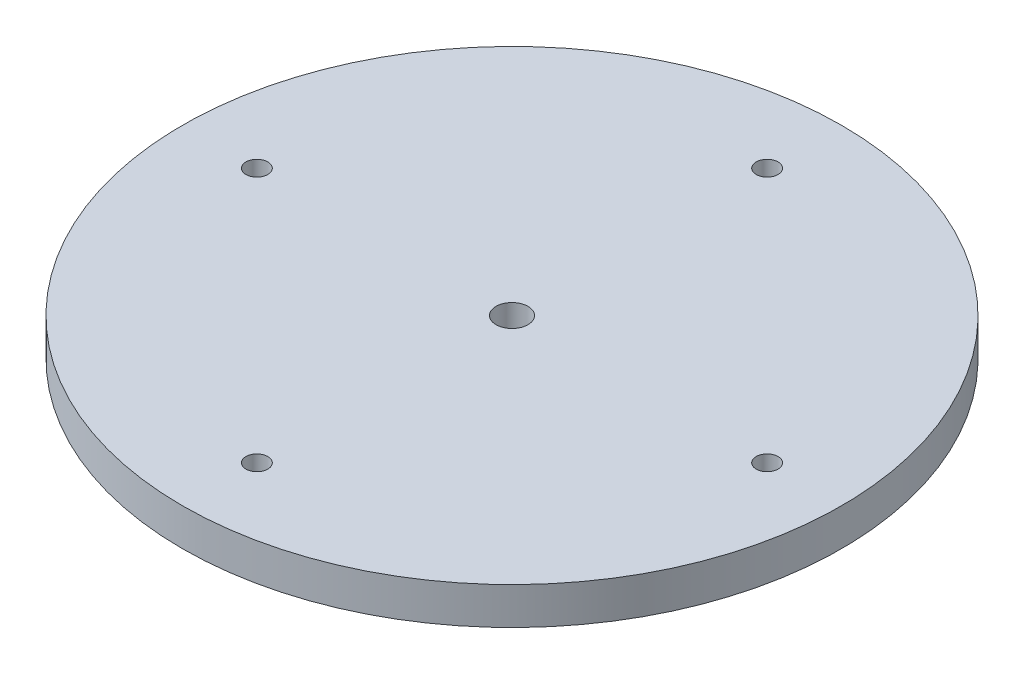
from build123d import *

# Parameters (mm, degrees)
SKETCH1_R                = 98.425
SKETCH1_R_2              = 4.7625
BOSS_EXTRUDE1_DEPTH      = 5.55625
BOSS_EXTRUDE1_DEPTH_BACK = 5.55625
CIRPATTERN1_COUNT        = 4


with BuildPart() as part:
    # Sketch1 → Boss-Extrude1 (new body, two sides)
    with BuildSketch(Plane(origin=(0, 0, 0), x_dir=(1, 0, 0), z_dir=(0, 1, 0))) as boss_extrude1_sk:
        Circle(SKETCH1_R)
        Circle(SKETCH1_R_2, mode=Mode.SUBTRACT)
    extrude(amount=BOSS_EXTRUDE1_DEPTH)
    extrude(boss_extrude1_sk.sketch, amount=-BOSS_EXTRUDE1_DEPTH_BACK)

    # Sketch2 → 1/4 Clearance Hole1 (revolve, cut)
    with BuildSketch(Plane(origin=(0, 5.55625, 76.2), x_dir=(0, 0, 1), z_dir=(1, 0, 0))):
        Polygon((0, 0), (0, 14.661148974), (3.2639, 12.7), (3.2639, 0), align=None)
    f_1_4_clearance_hole1 = revolve(axis=Axis((0, 11.90625, 76.2), (0, -1, 0)), mode=Mode.SUBTRACT)

    # CirPattern1: 1/4 Clearance Hole1 ×4 about axis
    cirpattern1_axis = Axis((0, 0, 0), (0, 1, 0))
    for i in range(1, CIRPATTERN1_COUNT):
        add(f_1_4_clearance_hole1.rotate(cirpattern1_axis, i * 360 / CIRPATTERN1_COUNT), mode=Mode.SUBTRACT)


solid = part.part
